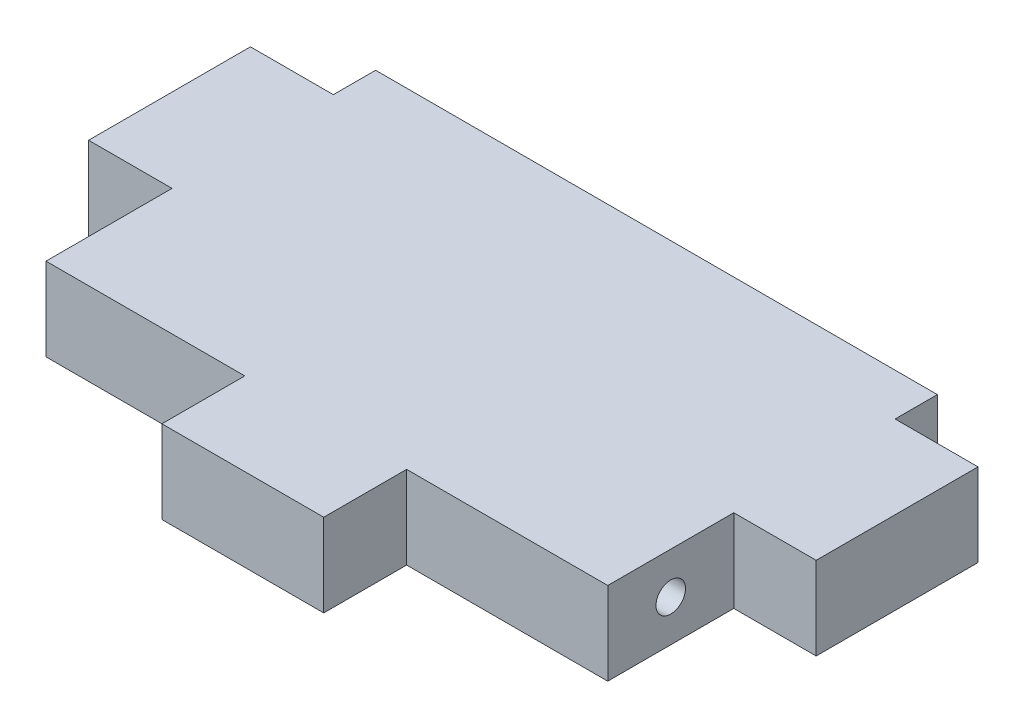
from build123d import *

# Parameters (mm, degrees)
BOSS_EXTRUDE1_DEPTH = 6.35
SKETCH3_R           = 1.1303
CUT_EXTRUDE1_DEPTH  = 12.7


with BuildPart() as part:
    # Sketch2 → Boss-Extrude1 (new body)
    with BuildSketch(Plane(origin=(0, 0, 0), x_dir=(1, 0, 0), z_dir=(0, 1, 0))):
        Polygon((-21.4249, -15.91216588), (-6.1976, -15.91216588), (-6.1976, -22.26216588), (6.1976, -22.26216588), (6.1976, -15.91216588), (21.6027, -15.91216588), (21.6027, -6.26016588), (27.914167201, -6.26016588), (27.914167201, 6.13503412), (21.564167201, 6.13503412), (21.564167201, 9.37353412), (-21.463432799, 9.37353412), (-21.463432799, 6.13503412), (-27.813432799, 6.13503412), (-27.813432799, -6.26016588), (-21.4249, -6.26016588), align=None)
    extrude(amount=BOSS_EXTRUDE1_DEPTH)

    # Sketch3 → Cut-Extrude1 (cut)
    with BuildSketch(Plane(origin=(21.6027, 0, 0), x_dir=(0, 0, -1), z_dir=(1, 0, 0))):
        with Locations((-11.08616588, 3.175)):
            Circle(SKETCH3_R)
    cut_extrude1 = extrude(amount=-CUT_EXTRUDE1_DEPTH, mode=Mode.SUBTRACT)

    # Mirror1: Cut-Extrude1 across plane
    add(cut_extrude1.mirror(Plane(origin=(0, 0, 0), x_dir=(0, 0, 1), z_dir=(1, 0, 0))), mode=Mode.SUBTRACT)


solid = part.part
